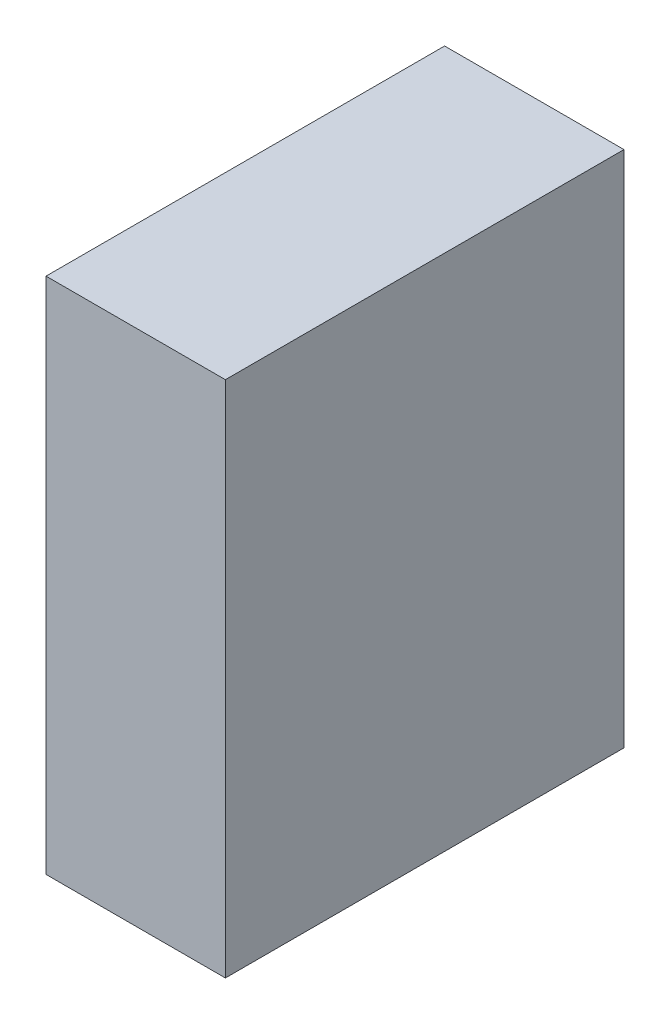
from build123d import *

# Parameters (mm, degrees)
MOTOR_CROSS_SECTION_W = 254
MOTOR_CROSS_SECTION_H = 330.2
MOTOR_DEPTH           = 57.15


with BuildPart() as part:
    # Motor Cross Section → Motor (new body, symmetric)
    with BuildSketch(Plane(origin=(0, 0, 0), x_dir=(0, 0, -1), z_dir=(1, 0, 0))):
        Rectangle(MOTOR_CROSS_SECTION_W, MOTOR_CROSS_SECTION_H)
    extrude(amount=MOTOR_DEPTH, both=True)


solid = part.part
